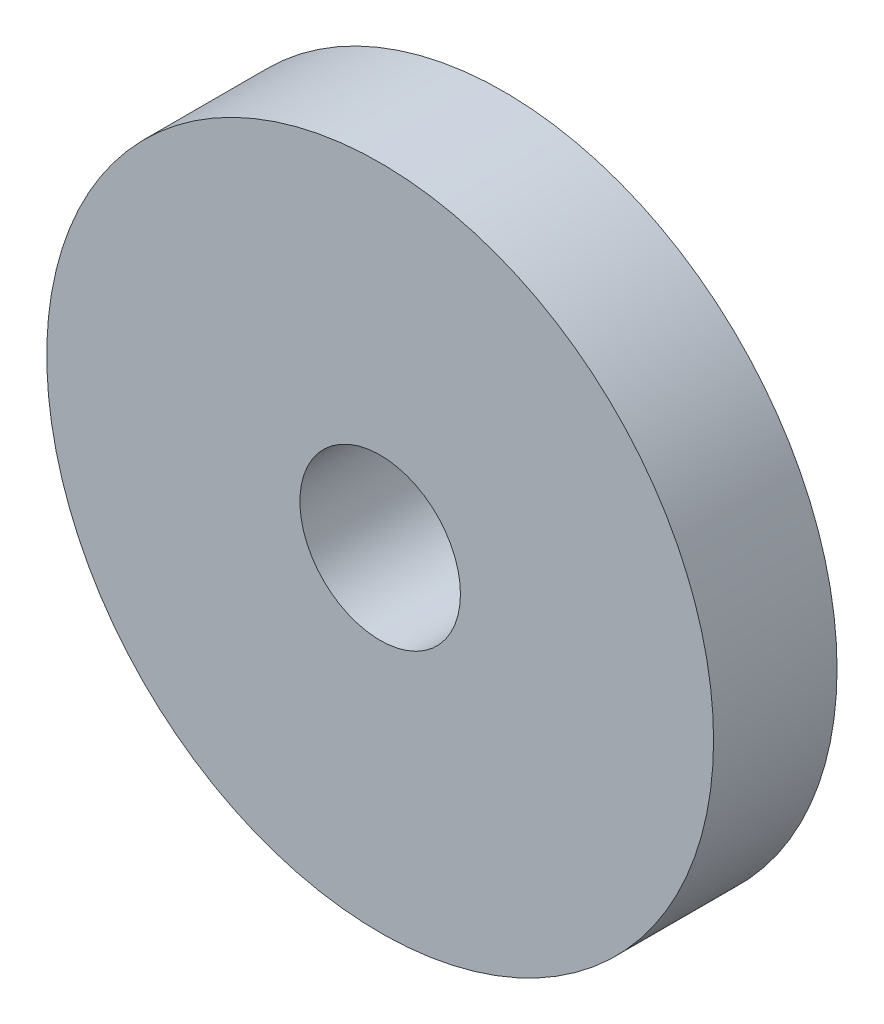
from build123d import *

# Parameters (mm, degrees)
SKETCH1_R           = 54
BOSS_EXTRUDE1_DEPTH = 20
CUT_EXTRUDE1_REACH  = 22
SKETCH2_R           = 13


with BuildPart() as part:
    # Sketch1 → Boss-Extrude1 (new body)
    with BuildSketch(Plane.XY):
        Circle(SKETCH1_R)
    extrude(amount=BOSS_EXTRUDE1_DEPTH)

    # Sketch2 → Cut-Extrude1 (cut, up to next)
    with BuildSketch(Plane.XY.offset(20), mode=Mode.PRIVATE) as cut_extrude1_sk1:
        Circle(SKETCH2_R)
    cut_extrude1_tool1 = extrude(cut_extrude1_sk1.sketch, amount=-CUT_EXTRUDE1_REACH, mode=Mode.PRIVATE) & part.part
    add(cut_extrude1_tool1.solids().sort_by_distance((0, 0, 20))[0], mode=Mode.SUBTRACT)


solid = part.part
